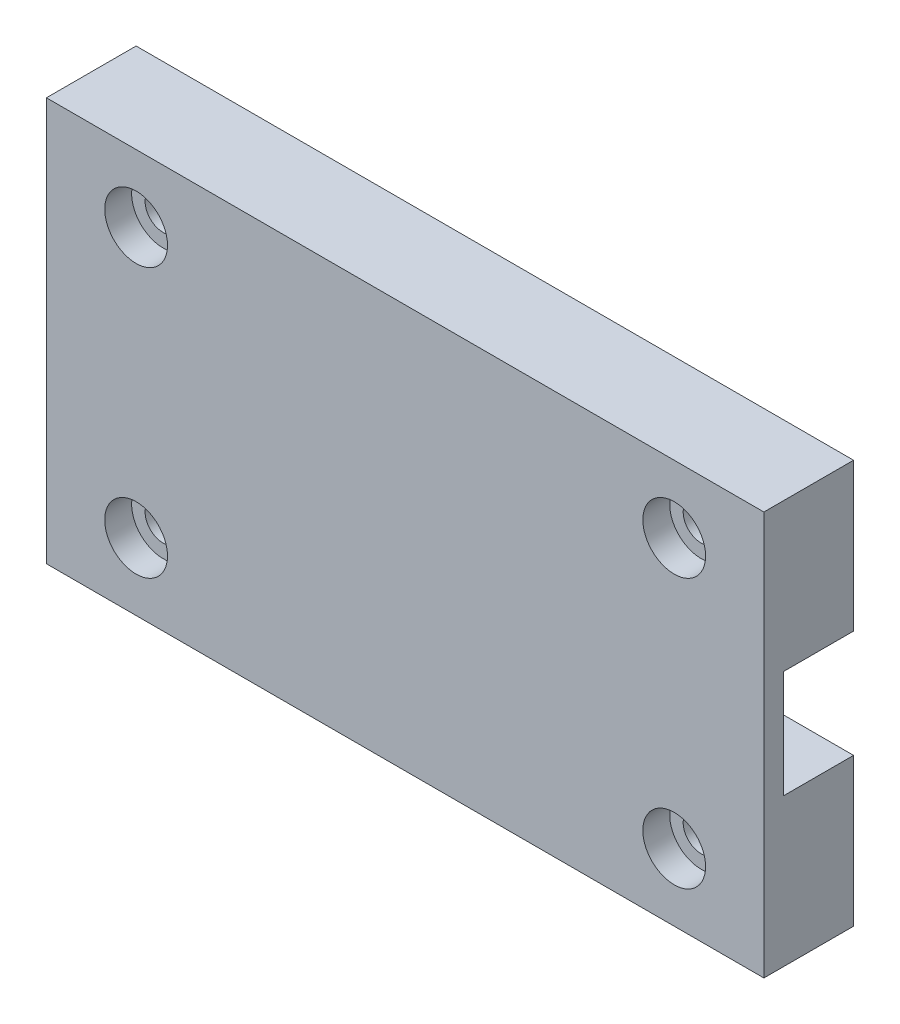
from build123d import *

# Parameters (mm, degrees)
SKETCH1_W           = 80
SKETCH1_H           = 45
BOSS_EXTRUDE1_DEPTH = 10
SKETCH2_W           = 110
SKETCH2_H           = 12
CUT_EXTRUDE1_DEPTH  = 7.8
SKETCH4_R           = 2
CUT_EXTRUDE3_DEPTH  = 11
SKETCH5_R           = 3.5
CUT_EXTRUDE4_DEPTH  = 3


with BuildPart() as part:
    # Sketch1 → Boss-Extrude1 (new body)
    with BuildSketch(Plane.XY):
        with Locations((40, 22.5)):
            Rectangle(SKETCH1_W, SKETCH1_H)
    extrude(amount=BOSS_EXTRUDE1_DEPTH)

    # Sketch2 → Cut-Extrude1 (cut)
    with BuildSketch(Plane(origin=(0, 0, 0), x_dir=(-1, 0, 0), z_dir=(0, 0, -1))):
        with Locations((-25, 22.5)):
            Rectangle(SKETCH2_W, SKETCH2_H)
    extrude(amount=-CUT_EXTRUDE1_DEPTH, mode=Mode.SUBTRACT)

    # Sketch4 → Cut-Extrude3 (cut, through all)
    with BuildSketch(Plane.XY.offset(10)):
        with Locations((10, 37.5)):
            Circle(SKETCH4_R)
        with Locations((70, 37.5)):
            Circle(SKETCH4_R)
        with Locations((70, 7.5)):
            Circle(SKETCH4_R)
        with Locations((10, 7.5)):
            Circle(SKETCH4_R)
    extrude(amount=-CUT_EXTRUDE3_DEPTH, mode=Mode.SUBTRACT)

    # Sketch5 → Cut-Extrude4 (cut)
    with BuildSketch(Plane.XY.offset(10)):
        with Locations((10, 37.5)):
            Circle(SKETCH5_R)
        with Locations((70, 37.5)):
            Circle(SKETCH5_R)
        with Locations((70, 7.5)):
            Circle(SKETCH5_R)
        with Locations((10, 7.5)):
            Circle(SKETCH5_R)
    extrude(amount=-CUT_EXTRUDE4_DEPTH, mode=Mode.SUBTRACT)


solid = part.part
